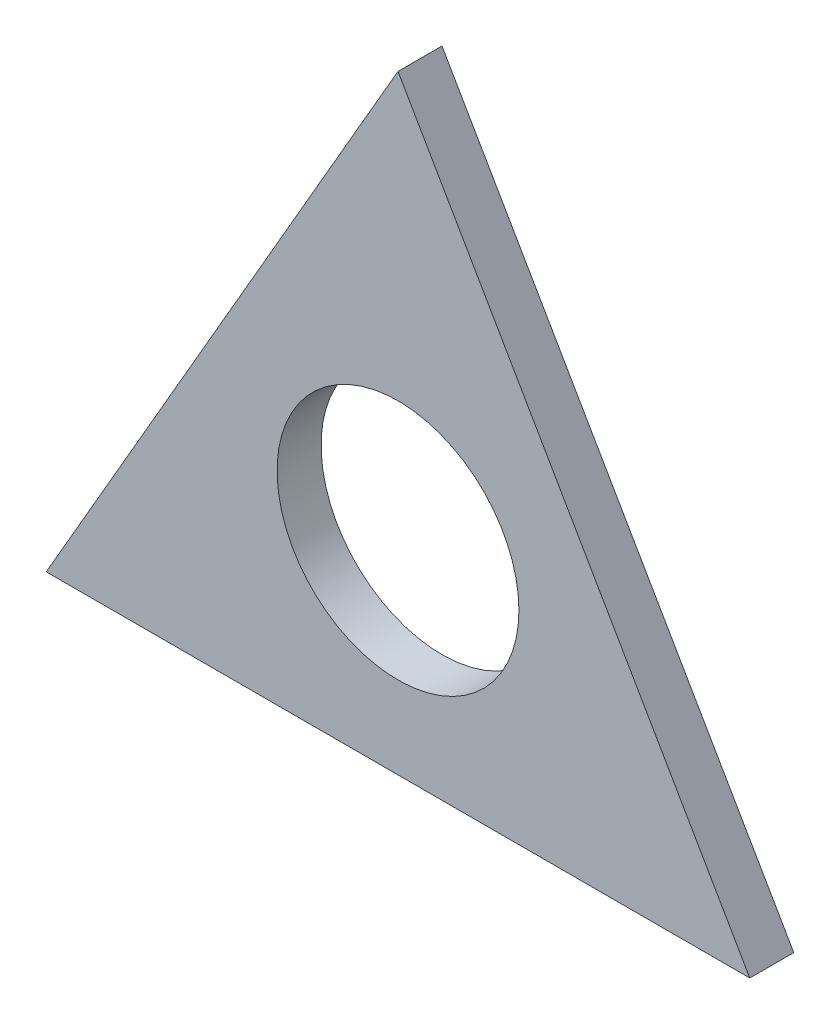
from build123d import *

# Parameters (mm, degrees)
BOSS_EXTRUDE1_DEPTH = 6.35
SKETCH2_R           = 17.4625
CUT_EXTRUDE1_DEPTH  = 7.35


with BuildPart() as part:
    # Sketch1 → Boss-Extrude1 (new body)
    with BuildSketch(Plane.XY):
        Polygon((0, 58.65878735), (-50.8, -29.329393675), (50.8, -29.329393675), align=None)
    extrude(amount=BOSS_EXTRUDE1_DEPTH)

    # Sketch2 → Cut-Extrude1 (cut, through all)
    with BuildSketch(Plane.XY.offset(6.35)):
        Circle(SKETCH2_R)
    extrude(amount=-CUT_EXTRUDE1_DEPTH, mode=Mode.SUBTRACT)


solid = part.part
